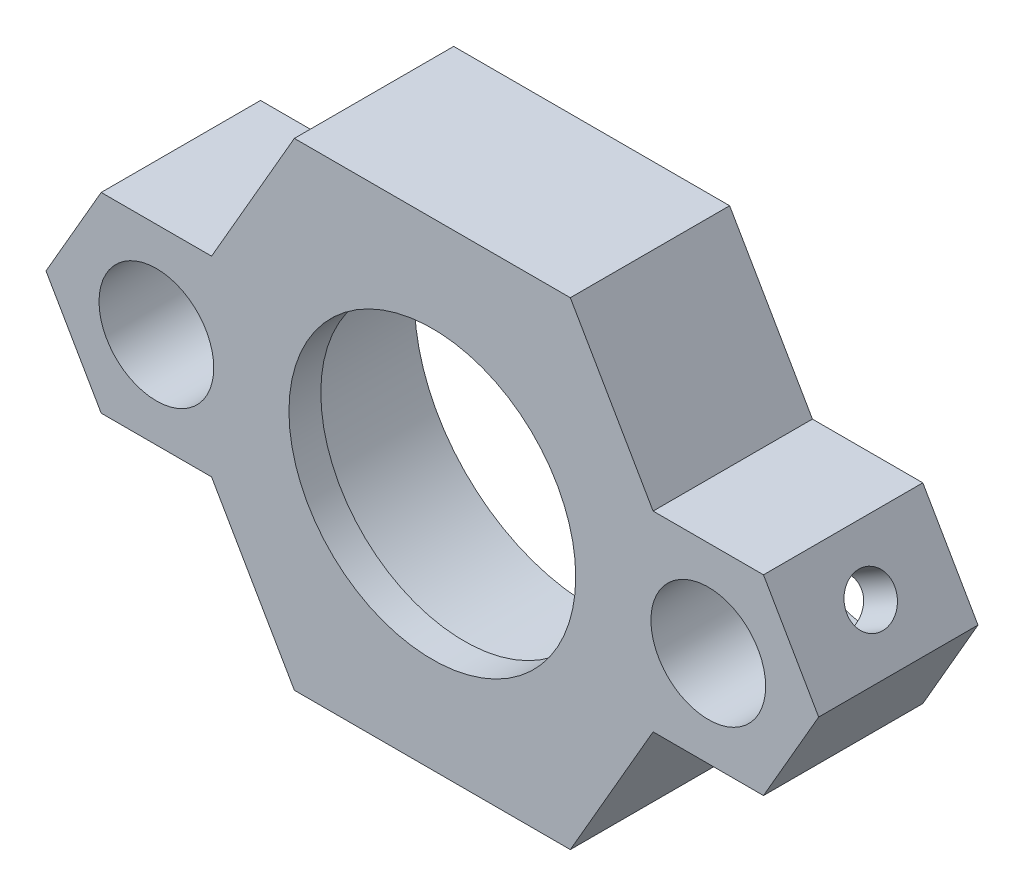
from build123d import *

# Parameters (mm, degrees)
SKETCH3_R           = 11.125
SKETCH3_R_2         = 3.6
BOSS_EXTRUDE1_DEPTH = 8
SKETCH4_R           = 9
SKETCH4_R_2         = 3.6
BOSS_EXTRUDE3_DEPTH = 2
CUT_EXTRUDE1_REACH  = 51.5
SKETCH5_R           = 1.5
CUT_EXTRUDE2_REACH  = 51.5
SKETCH6_R           = 1.5


with BuildPart() as part:
    # Sketch3 → Boss-Extrude1 (new body)
    with BuildSketch(Plane.XY):
        Polygon((8.660254038, 15), (-8.660254038, 15), (-13.856406461, 6), (-20.784609691, 6), (-24.248711306, 0), (-20.784609691, -6), (-13.856406461, -6), (-8.660254038, -15), (8.660254038, -15), (13.856406461, -6), (20.784609691, -6), (24.248711306, 0), (20.784609691, 6), (13.856406461, 6), align=None)
        Circle(SKETCH3_R, mode=Mode.SUBTRACT)
        with Locations((17.320508076, 0)):
            Circle(SKETCH3_R_2, mode=Mode.SUBTRACT)
        with Locations((-17.320508076, 0)):
            Circle(SKETCH3_R_2, mode=Mode.SUBTRACT)
    extrude(amount=BOSS_EXTRUDE1_DEPTH)

    # Sketch4 → Boss-Extrude3 (add)
    with BuildSketch(Plane.XY.offset(8)):
        Polygon((-8.660254038, 15), (-13.856406461, 6), (-20.784609691, 6), (-24.248711306, 0), (-20.784609691, -6), (-13.856406461, -6), (-8.660254038, -15), (8.660254038, -15), (13.856406461, -6), (20.784609691, -6), (24.248711306, 0), (20.784609691, 6), (13.856406461, 6), (8.660254038, 15), align=None)
        Circle(SKETCH4_R, mode=Mode.SUBTRACT)
        with Locations((-17.320508076, 0)):
            Circle(SKETCH4_R_2, mode=Mode.SUBTRACT)
        with Locations((17.320508076, 0)):
            Circle(SKETCH4_R_2, mode=Mode.SUBTRACT)
    extrude(amount=BOSS_EXTRUDE3_DEPTH)

    # Sketch5 → Cut-Extrude1 (cut, up to next)
    with BuildSketch(Plane(origin=(-18.186533479, 10.5, 0), x_dir=(0, 0, 1), z_dir=(-0.866025404, 0.5, 0)), mode=Mode.PRIVATE) as cut_extrude1_sk1:
        with Locations((5, -8.660254038)):
            Circle(SKETCH5_R)
    cut_extrude1_tool1 = extrude(cut_extrude1_sk1.sketch, amount=-CUT_EXTRUDE1_REACH, mode=Mode.PRIVATE) & part.part
    add(cut_extrude1_tool1.solids().sort_by_distance((-22.51666, 3, 5))[0], mode=Mode.SUBTRACT)

    # Sketch6 → Cut-Extrude2 (cut, up to next)
    with BuildSketch(Plane(origin=(18.186533479, 10.5, 0), x_dir=(0, 0, -1), z_dir=(0.866025404, 0.5, 0)), mode=Mode.PRIVATE) as cut_extrude2_sk1:
        with Locations((-5, -8.660254038)):
            Circle(SKETCH6_R)
    cut_extrude2_tool1 = extrude(cut_extrude2_sk1.sketch, amount=-CUT_EXTRUDE2_REACH, mode=Mode.PRIVATE) & part.part
    add(cut_extrude2_tool1.solids().sort_by_distance((22.51666, 3, 5))[0], mode=Mode.SUBTRACT)


solid = part.part
